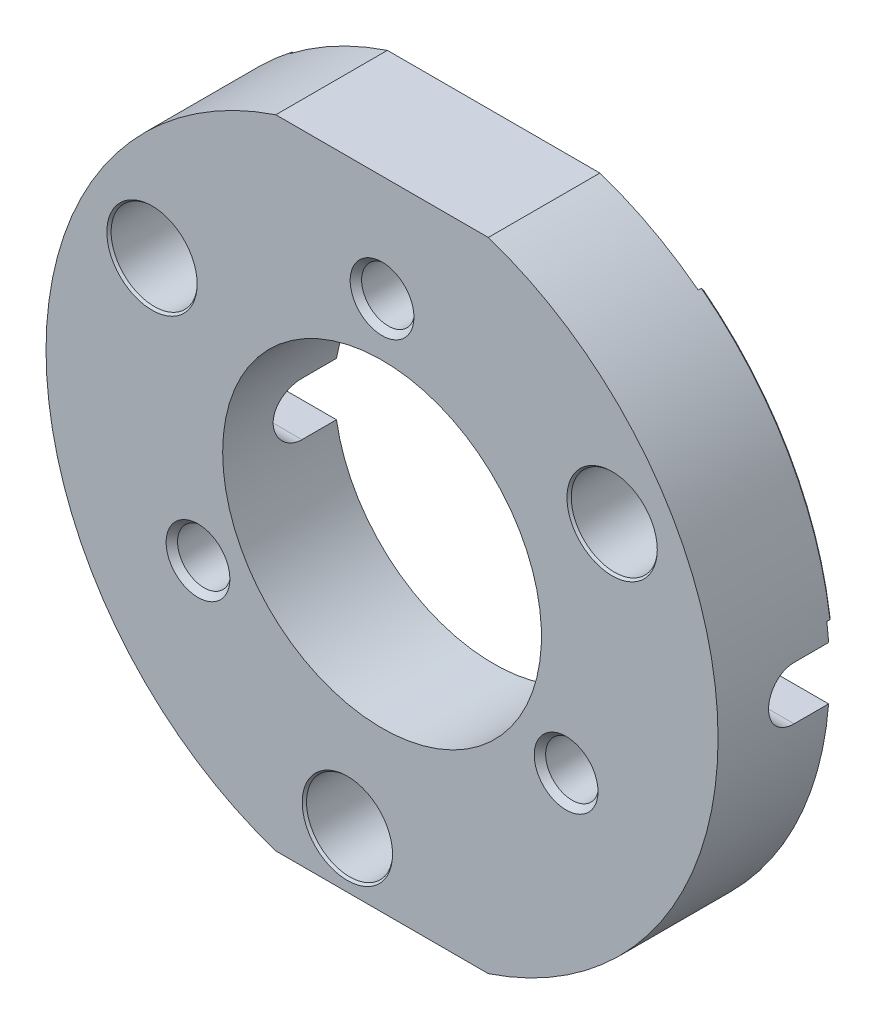
from build123d import *

# Parameters (mm, degrees)
EXTRUDE1_DEPTH                                = 27.94
CBORE_FOR_1_2_SOCKET_HEAD_CAP_SCREW1_AT_COUNT = 2
CBORE_FOR_1_2_SOCKET_HEAD_CAP_SCREW1_AT_PITCH = 109.985226281
CBORE_FOR_1_2_SOCKET_HEAD_CAP_SCREW1_2_COUNT  = 2
CBORE_FOR_1_2_SOCKET_HEAD_CAP_SCREW1_2_PITCH  = 105.596640762
SKETCH6_R                                     = 38.1
CUT_EXTRUDE1_DEPTH                            = 28.94
CUT_EXTRUDE3_DEPTH                            = 81.321852568
CUT_EXTRUDE3_DEPTH_BACK                       = 81.321852568
CUT_EXTRUDE2_DEPTH                            = 1.27
F_1_2_20_TAPPED_HOLE1_D                       = 12.7
F_1_2_20_TAPPED_HOLE1_CSINK_D                 = 15.24
F_1_2_20_TAPPED_HOLE1_CSINK_ANGLE             = 82
SKETCH11_R                                    = 44.45
CUT_EXTRUDE4_DEPTH                            = 1.27
CHAMFER1_SIZE                                 = 0.508


with BuildPart() as part:
    # Sketch1 → Extrude1 (new body)
    with BuildSketch(Plane.XY):
        with BuildLine():
            Line((-25.4, 76.2), (25.4, 76.2))
            ThreePointArc((25.4, 76.2), (80.321852568, 0), (25.4, -76.2))
            Line((25.4, -76.2), (-25.4, -76.2))
            ThreePointArc((-25.4, -76.2), (-80.321852568, 0), (-25.4, 76.2))
        make_face()
    extrude(amount=EXTRUDE1_DEPTH)

    # Sketch3 → CBORE for 1_2 Socket Head Cap Screw1 (revolve, cut)
    with BuildSketch(Plane(origin=(-54.99261314, 31.75, 27.94), x_dir=(0, -1, 0), z_dir=(1, 0, 0))):
        Polygon((0, 0), (0, 27.94), (7.62, 27.94), (6.94563, 27.164226057), (6.94563, 15.24), (10.31875, 15.24), (10.31875, 0.547862954), (10.795, 0), align=None)
    cbore_for_1_2_socket_head_cap_screw1 = revolve(axis=Axis((-54.99261314, 31.75, 34.29), (0, 0, -1)), mode=Mode.SUBTRACT)

    # CBORE for 1_2 Socket Head Cap Screw1 at: CBORE for 1_2 Socket Head Cap Screw1 ×2
    with Locations(*[(i * CBORE_FOR_1_2_SOCKET_HEAD_CAP_SCREW1_AT_PITCH, 0, 0) for i in range(1, CBORE_FOR_1_2_SOCKET_HEAD_CAP_SCREW1_AT_COUNT)]):
        add(cbore_for_1_2_socket_head_cap_screw1, mode=Mode.SUBTRACT)

    # CBORE for 1_2 Socket Head Cap Screw1 2: CBORE for 1_2 Socket Head Cap Screw1 ×2
    with Locations(*[Vector(0.44228869, -0.896872742, 0) * (i * CBORE_FOR_1_2_SOCKET_HEAD_CAP_SCREW1_2_PITCH) for i in range(1, CBORE_FOR_1_2_SOCKET_HEAD_CAP_SCREW1_2_COUNT)]):
        add(cbore_for_1_2_socket_head_cap_screw1, mode=Mode.SUBTRACT)

    # Sketch6 → Cut-Extrude1 (cut, through all)
    with BuildSketch(Plane(origin=(0, 0, 0), x_dir=(-1, 0, 0), z_dir=(0, 0, -1))):
        Circle(SKETCH6_R)
    extrude(amount=-CUT_EXTRUDE1_DEPTH, mode=Mode.SUBTRACT)

    # Sketch10 → Cut-Extrude3 (cut, two sides)
    with BuildSketch(Plane(origin=(0, 0, 0), x_dir=(0, 0, -1), z_dir=(1, 0, 0))) as cut_extrude3_sk:
        with BuildLine():
            Line((0, 6.35), (-9.525, 6.35))
            ThreePointArc((-9.525, 6.35), (-15.875, 0), (-9.525, -6.35))
            Line((-9.525, -6.35), (0, -6.35))
            Line((0, -6.35), (0, 6.35))
        make_face()
    extrude(amount=CUT_EXTRUDE3_DEPTH, mode=Mode.SUBTRACT)
    extrude(cut_extrude3_sk.sketch, amount=-CUT_EXTRUDE3_DEPTH_BACK, mode=Mode.SUBTRACT)

    # Sketch9 → Cut-Extrude2 (cut)
    with BuildSketch(Plane(origin=(0, 0, 0), x_dir=(-1, 0, 0), z_dir=(0, 0, -1))):
        with BuildLine():
            Line((-79.634687985, 10.484105568), (-37.774049218, 4.973047924))
            ThreePointArc((-37.774049218, 4.973047924), (-32.995567884, -19.05), (-14.580238773, -35.199810189))
            Line((-14.580238773, -35.199810189), (-30.737842235, -74.207715601))
            ThreePointArc((-30.737842235, -74.207715601), (-69.560764803, -40.160926284), (-79.634687985, 10.484105568))
        make_face()
        with BuildLine():
            Line((-48.89684575, 63.723610033), (-23.193810445, 30.226762265))
            ThreePointArc((-23.193810445, 30.226762265), (0, 38.1), (23.193810445, 30.226762265))
            Line((23.193810445, 30.226762265), (48.89684575, 63.723610033))
            ThreePointArc((48.89684575, 63.723610033), (0, 80.321852568), (-48.89684575, 63.723610033))
        make_face()
        with BuildLine():
            Line((37.774049218, 4.973047924), (79.634687985, 10.484105568))
            ThreePointArc((79.634687985, 10.484105568), (69.560764803, -40.160926284), (30.737842235, -74.207715601))
            Line((30.737842235, -74.207715601), (14.580238773, -35.199810189))
            ThreePointArc((14.580238773, -35.199810189), (32.995567884, -19.05), (37.774049218, 4.973047924))
        make_face()
    extrude(amount=-CUT_EXTRUDE2_DEPTH, mode=Mode.SUBTRACT)

    # 1_2-20 Tapped Hole1 (through all)
    with Locations(Plane.XY.offset(27.94)):
        with Locations((0, 50.8), (-43.994090512, -25.4), (43.994090512, -25.4)):
            CounterSinkHole(F_1_2_20_TAPPED_HOLE1_D / 2, F_1_2_20_TAPPED_HOLE1_CSINK_D / 2, counter_sink_angle=F_1_2_20_TAPPED_HOLE1_CSINK_ANGLE)

    # Sketch11 → Cut-Extrude4 (cut)
    with BuildSketch(Plane(origin=(0, 0, 0), x_dir=(-1, 0, 0), z_dir=(0, 0, -1))):
        Circle(SKETCH11_R)
    extrude(amount=-CUT_EXTRUDE4_DEPTH, mode=Mode.SUBTRACT)

    # Chamfer1
    chamfer1_edges = [part.edges().sort_by_distance(p)[0] for p in [
        (-28.086591676, -75.251201771, 0),
        (-69.560764803, 40.160926284, 0),
        (0, -76.2, 0),
        (-37.978145635, 49.494083005, 0),
        (-38.355757488, 22.464157396, 0),
        (-46.113564564, 6.35, 0),
        (-63.9338633, 8.417052784, 0),
        (46.113564564, 6.35, 0),
        (38.355757488, 22.464157396, 0),
        (37.978145635, 49.494083005, 0),
        (63.9338633, 8.417052784, 0),
        (69.560764803, 40.160926284, 0),
        (0, -44.45, 0),
        (23.874060402, -57.637080411, 0),
        (-23.874060402, -57.637080411, 0),
        (28.086591676, -75.251201771, 0),
    ]]
    chamfer(chamfer1_edges, length=CHAMFER1_SIZE)


solid = part.part
